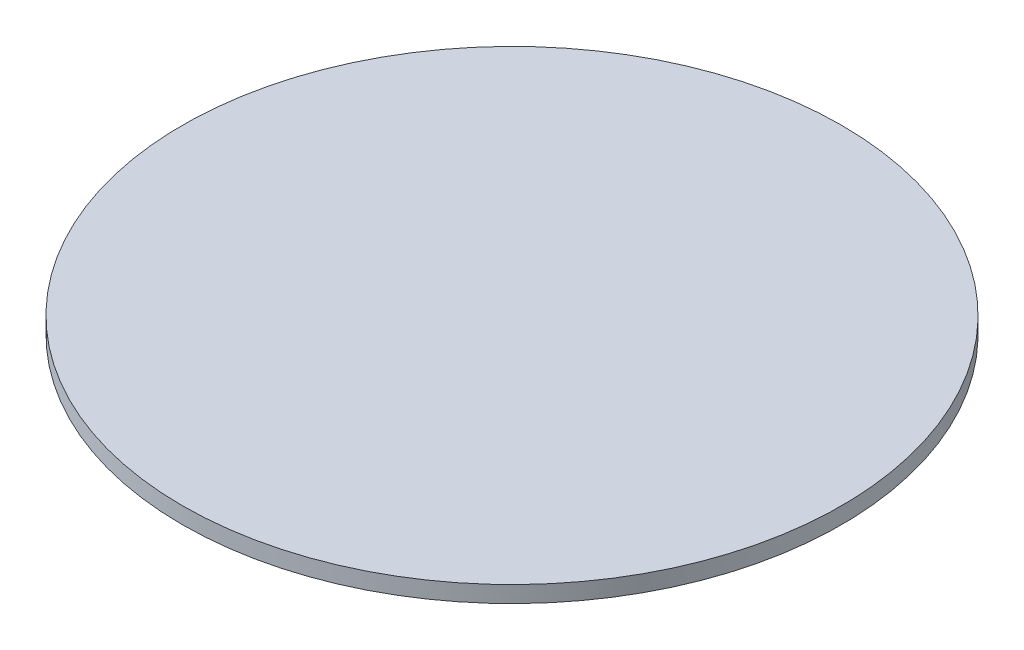
from build123d import *

# Parameters (mm, degrees)
ESQUISSE1_R        = 20
BOSS_EXTRU_1_DEPTH = 1


with BuildPart() as part:
    # Esquisse1 → Boss.-Extru.1 (new body)
    with BuildSketch(Plane(origin=(0, 0, 0), x_dir=(1, 0, 0), z_dir=(0, 1, 0))):
        Circle(ESQUISSE1_R)
    extrude(amount=BOSS_EXTRU_1_DEPTH)


solid = part.part
